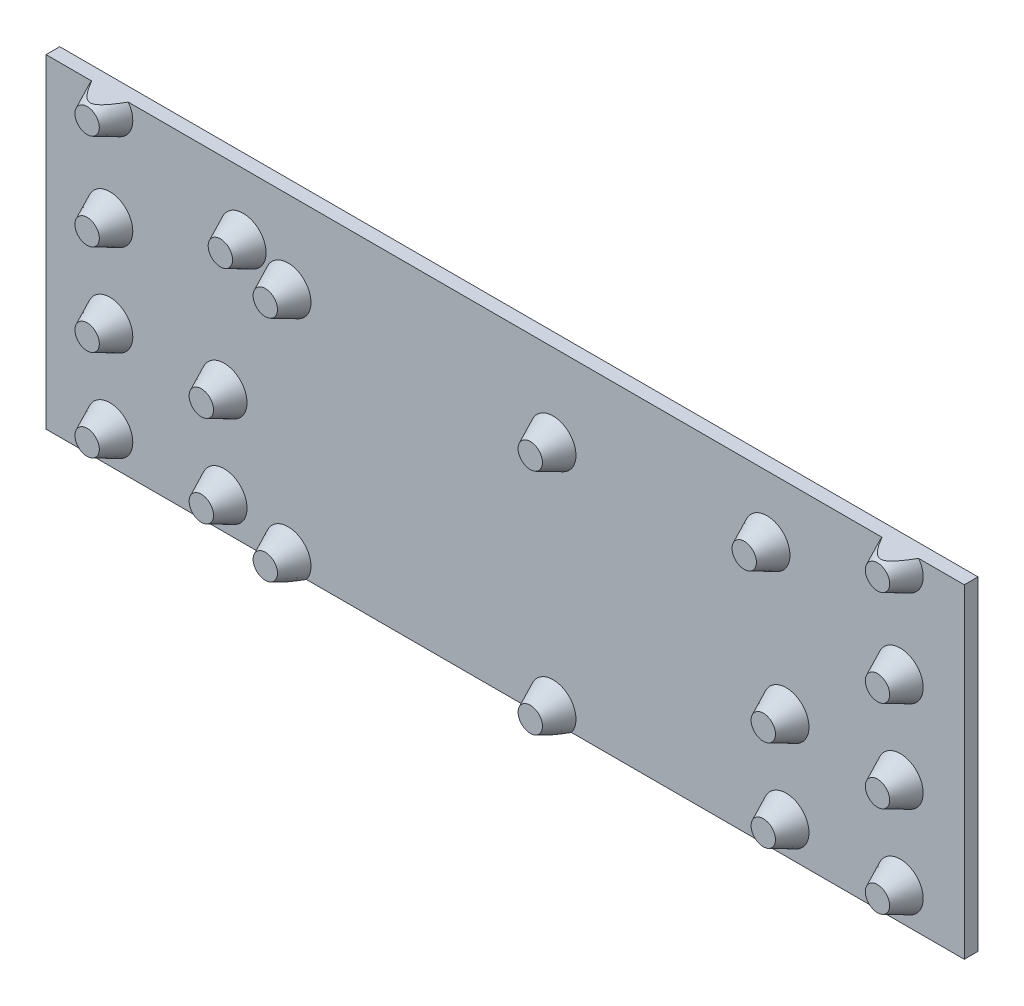
from build123d import *

# Parameters (mm, degrees)
ESQUISSE2_W             = 201
ESQUISSE2_H             = 75
BOSS_EXTRU_1_DEPTH      = 3
ESQUISSE3_R             = 5
ESQUISSE3_R_2           = 4.999999998
BOSS_EXTRU_3_DEPTH      = 5
BOSS_EXTRU_3_TAPER      = 25
ESQUISSE4_W             = 210
ESQUISSE4_H             = 11.155958732
ENL_V_MAT_EXTRU_1_DEPTH = 2
ESQUISSE5_W             = 220
ESQUISSE5_H             = 18.927618919
ENL_V_MAT_EXTRU_2_DEPTH = 2


with BuildPart() as part:
    # Esquisse2 → Boss.-Extru.1 (new body)
    with BuildSketch(Plane.XY):
        with Locations((0.446886155, -8.200471698)):
            Rectangle(ESQUISSE2_W, ESQUISSE2_H)
    extrude(amount=BOSS_EXTRU_1_DEPTH)

    # Esquisse3 → Boss.-Extru.3 (add)
    with BuildSketch(Plane.XY.offset(3)):
        with Locations((-47.053113845, 9.299528302)):
            Circle(ESQUISSE3_R)
        with Locations((-47.053113845, -40.700471698)):
            Circle(ESQUISSE3_R)
        with Locations((10.946886143, 9.300717009)):
            Circle(ESQUISSE3_R)
        with Locations((10.946886143, -40.699282991)):
            Circle(ESQUISSE3_R)
        with Locations((-86.053113845, 24.299528302)):
            Circle(ESQUISSE3_R)
        with Locations((-56.885494813, 13.799528302)):
            Circle(ESQUISSE3_R)
        with Locations((-86.053113845, 3.299528302)):
            Circle(ESQUISSE3_R)
        with Locations((-86.053113845, -16.700471698)):
            Circle(ESQUISSE3_R)
        with Locations((-86.053113845, -36.700471698)):
            Circle(ESQUISSE3_R)
        with Locations((-61.053113845, -16.700471698)):
            Circle(ESQUISSE3_R_2)
        with Locations((-61.053113845, -36.700471698)):
            Circle(ESQUISSE3_R_2)
        with Locations((86.946886155, 24.299361822)):
            Circle(ESQUISSE3_R)
        with Locations((86.946886155, 3.299528302)):
            Circle(ESQUISSE3_R)
        with Locations((57.779237158, 13.799445062)):
            Circle(ESQUISSE3_R)
        with Locations((86.946886155, -16.700471698)):
            Circle(ESQUISSE3_R)
        with Locations((86.946886155, -36.700471698)):
            Circle(ESQUISSE3_R)
        with Locations((61.946886155, -36.700471698)):
            Circle(ESQUISSE3_R)
        with Locations((61.946886155, -16.700471698)):
            Circle(ESQUISSE3_R)
    extrude(amount=BOSS_EXTRU_3_DEPTH, taper=BOSS_EXTRU_3_TAPER)

    # Esquisse4 → Enlèv. mat.-Extru.1 (cut)
    with BuildSketch(Plane(origin=(0, 29.299528302, 0), x_dir=(1, 0, 0), z_dir=(0, 1, 0))):
        with Locations((1.418471148, -5.577979366)):
            Rectangle(ESQUISSE4_W, ESQUISSE4_H)
    extrude(amount=-ENL_V_MAT_EXTRU_1_DEPTH, mode=Mode.SUBTRACT)

    # Esquisse5 → Enlèv. mat.-Extru.2 (cut)
    with BuildSketch(Plane(origin=(0, -45.700471698, 0), x_dir=(-1, 0, 0), z_dir=(0, -1, 0))):
        with Locations((0.053113845, -9.46380946)):
            Rectangle(ESQUISSE5_W, ESQUISSE5_H)
    extrude(amount=-ENL_V_MAT_EXTRU_2_DEPTH, mode=Mode.SUBTRACT)


solid = part.part
